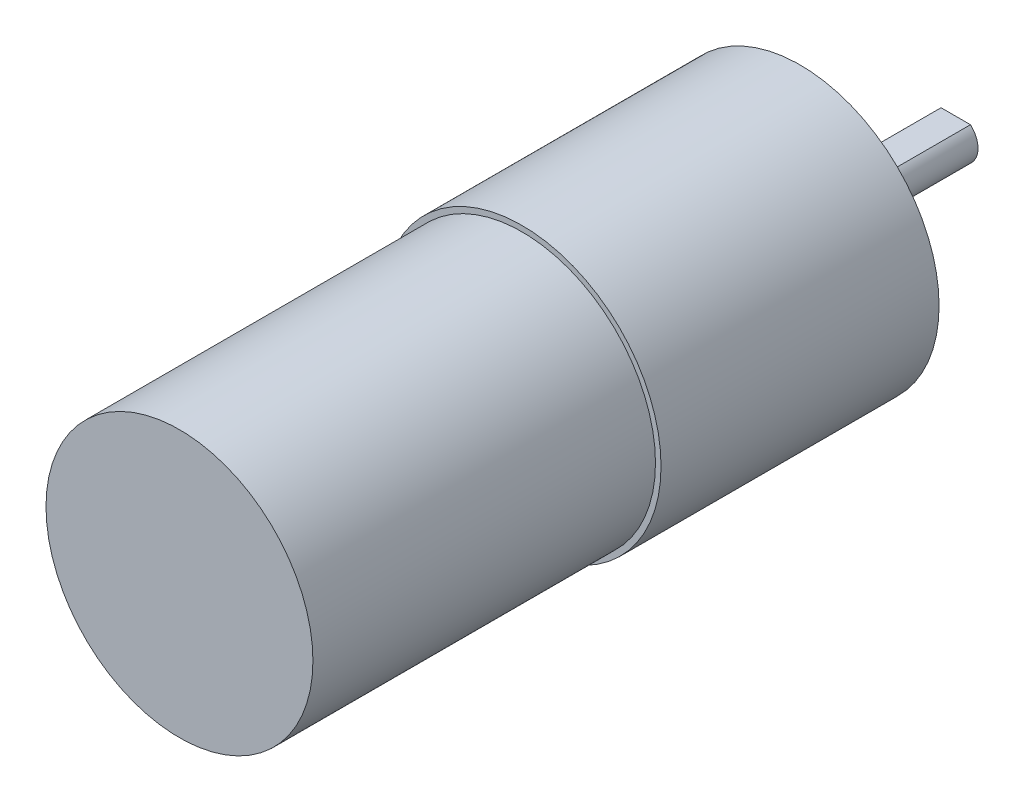
from build123d import *

# Parameters (mm, degrees)
SKETCH1_R           = 12.5
BOSS_EXTRUDE2_DEPTH = 25
SKETCH2_R           = 3
BOSS_EXTRUDE3_DEPTH = 2
SKETCH3_R           = 2
BOSS_EXTRUDE4_DEPTH = 12
CUT_EXTRUDE1_DEPTH  = 12
SKETCH5_R           = 12
BOSS_EXTRUDE5_DEPTH = 30.8


with BuildPart() as part:
    # Sketch1 → Boss-Extrude2 (new body)
    with BuildSketch(Plane.XY):
        Circle(SKETCH1_R)
    extrude(amount=BOSS_EXTRUDE2_DEPTH)

    # Sketch2 → Boss-Extrude3 (add)
    with BuildSketch(Plane(origin=(0, 0, 0), x_dir=(-1, 0, 0), z_dir=(0, 0, -1))):
        Circle(SKETCH2_R)
    extrude(amount=BOSS_EXTRUDE3_DEPTH)

    # Sketch3 → Boss-Extrude4 (add)
    with BuildSketch(Plane(origin=(0, 0, -2), x_dir=(-1, 0, 0), z_dir=(0, 0, -1))):
        Circle(SKETCH3_R)
    extrude(amount=BOSS_EXTRUDE4_DEPTH)

    # Sketch4 → Cut-Extrude1 (cut)
    with BuildSketch(Plane(origin=(0, 0, -14), x_dir=(-1, 0, 0), z_dir=(0, 0, -1))):
        with BuildLine():
            Line((-1.322875656, 1.5), (1.322875656, 1.5))
            ThreePointArc((1.322875656, 1.5), (0, 2), (-1.322875656, 1.5))
        make_face()
    extrude(amount=-CUT_EXTRUDE1_DEPTH, mode=Mode.SUBTRACT)

    # Sketch5 → Boss-Extrude5 (add)
    with BuildSketch(Plane.XY.offset(25)):
        Circle(SKETCH5_R)
    extrude(amount=BOSS_EXTRUDE5_DEPTH)


solid = part.part
